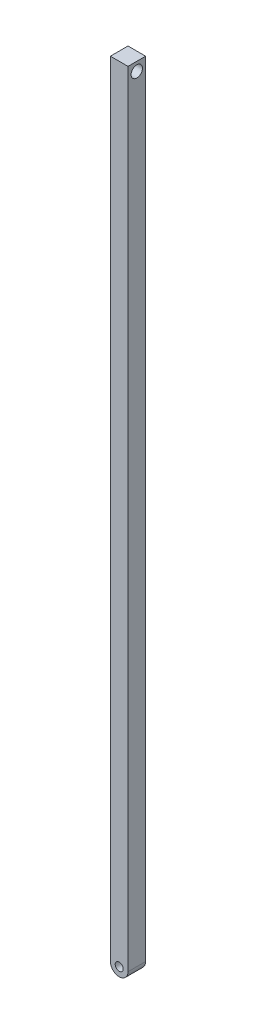
from build123d import *

# Parameters (mm, degrees)
SKETCH1_R           = 0.227761077
BOSS_EXTRUDE1_DEPTH = 1
SKETCH2_R           = 0.323069994
CUT_EXTRUDE1_DEPTH  = 2


with BuildPart() as part:
    # Sketch1 → Boss-Extrude1 (new body)
    with BuildSketch(Plane.XY):
        with BuildLine():
            Line((3.443773372, -22.256132879), (3.443773372, -66.7561317))
            ThreePointArc((3.443773372, -66.7561317), (3.943772783, -67.256132289), (4.443773372, -66.756132879))
            Line((4.443773372, -66.756132879), (4.443773372, -22.256132879))
            Line((4.443773372, -22.256132879), (3.443773372, -22.256132879))
        make_face()
        with Locations((3.943773372, -66.756132289)):
            Circle(SKETCH1_R, mode=Mode.SUBTRACT)
    extrude(amount=BOSS_EXTRUDE1_DEPTH)

    # Sketch2 → Cut-Extrude1 (cut, through all)
    with BuildSketch(Plane(origin=(4.443773372, 0, 0), x_dir=(0, 0, -1), z_dir=(1, 0, 0))):
        with Locations((-0.5, -22.756132879)):
            Circle(SKETCH2_R)
    extrude(amount=-CUT_EXTRUDE1_DEPTH, mode=Mode.SUBTRACT)


solid = part.part
